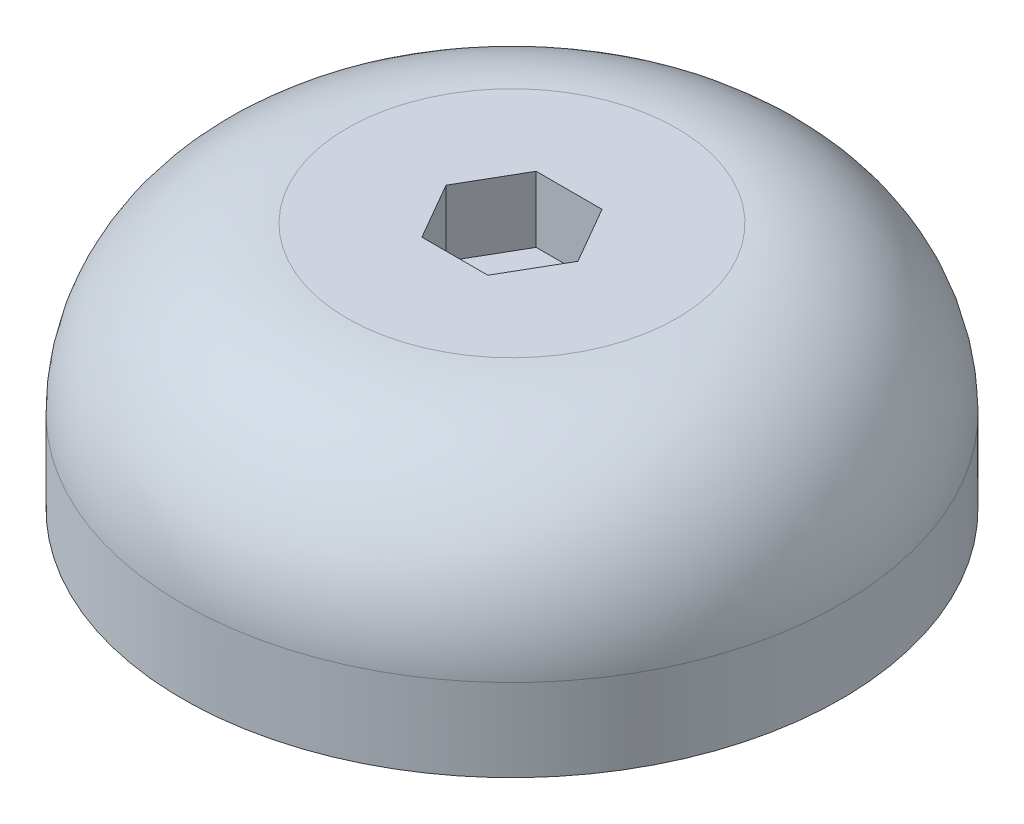
from build123d import *

# Parameters (mm, degrees)
SKETCH1_R           = 9.75
SKETCH1_R_2         = 2
BOSS_EXTRUDE1_DEPTH = 3
SKETCH2_W           = 3.2
SKETCH2_H           = 3.2
CUT_EXTRUDE1_DEPTH  = 3
SKETCH3_R           = 20
BOSS_EXTRUDE2_DEPTH = 8
SKETCH4_R           = 20
SKETCH4_R_2         = 9.75
BOSS_EXTRUDE3_DEPTH = 7
FILLET2_R           = 10
SKETCH5_R           = 2
CUT_EXTRUDE2_DEPTH  = 9
CUT_EXTRUDE3_DEPTH  = 4
FILLET3_R           = 0.5


with BuildPart() as part:
    # Sketch1 → Boss-Extrude1 (new body)
    with BuildSketch(Plane(origin=(0, 0, 0), x_dir=(1, 0, 0), z_dir=(0, 1, 0))):
        Circle(SKETCH1_R)
        Circle(SKETCH1_R_2, mode=Mode.SUBTRACT)
    extrude(amount=BOSS_EXTRUDE1_DEPTH)

    # Sketch2 → Cut-Extrude1 (cut)
    with BuildSketch(Plane.XZ):
        with Locations((-0.030329448, -6.016441714)):
            Rectangle(SKETCH2_W, SKETCH2_H)
    extrude(amount=-CUT_EXTRUDE1_DEPTH, mode=Mode.SUBTRACT)

    # Sketch3 → Boss-Extrude2 (add)
    with BuildSketch(Plane(origin=(0, 3, 0), x_dir=(1, 0, 0), z_dir=(0, 1, 0))):
        Circle(SKETCH3_R)
    extrude(amount=BOSS_EXTRUDE2_DEPTH)

    # Sketch4 → Boss-Extrude3 (add)
    with BuildSketch(Plane.XZ.offset(-3)):
        Circle(SKETCH4_R)
        Circle(SKETCH4_R_2, mode=Mode.SUBTRACT)
    extrude(amount=BOSS_EXTRUDE3_DEPTH)

    # Fillet2
    fillet2_edges = [part.edges().sort_by_distance(p)[0] for p in [
        (-20, 11, 0),
    ]]
    fillet(fillet2_edges, radius=FILLET2_R)

    # Sketch5 → Cut-Extrude2 (cut, through all)
    with BuildSketch(Plane.XZ.offset(-3)):
        Circle(SKETCH5_R)
    extrude(amount=-CUT_EXTRUDE2_DEPTH, mode=Mode.SUBTRACT)

    # Sketch6 → Cut-Extrude3 (cut)
    with BuildSketch(Plane(origin=(0, 11, 0), x_dir=(1, 0, 0), z_dir=(0, 1, 0))):
        Polygon((4.001037365, 0), (2.000518683, 3.465), (-2.000518683, 3.465), (-4.001037365, 0), (-2.000518683, -3.465), (2.000518683, -3.465), align=None)
    extrude(amount=-CUT_EXTRUDE3_DEPTH, mode=Mode.SUBTRACT)

    # Fillet3
    fillet3_edges = [part.edges().sort_by_distance(p)[0] for p in [
        (-9.75, -4, 0),
    ]]
    fillet(fillet3_edges, radius=FILLET3_R)


solid = part.part
